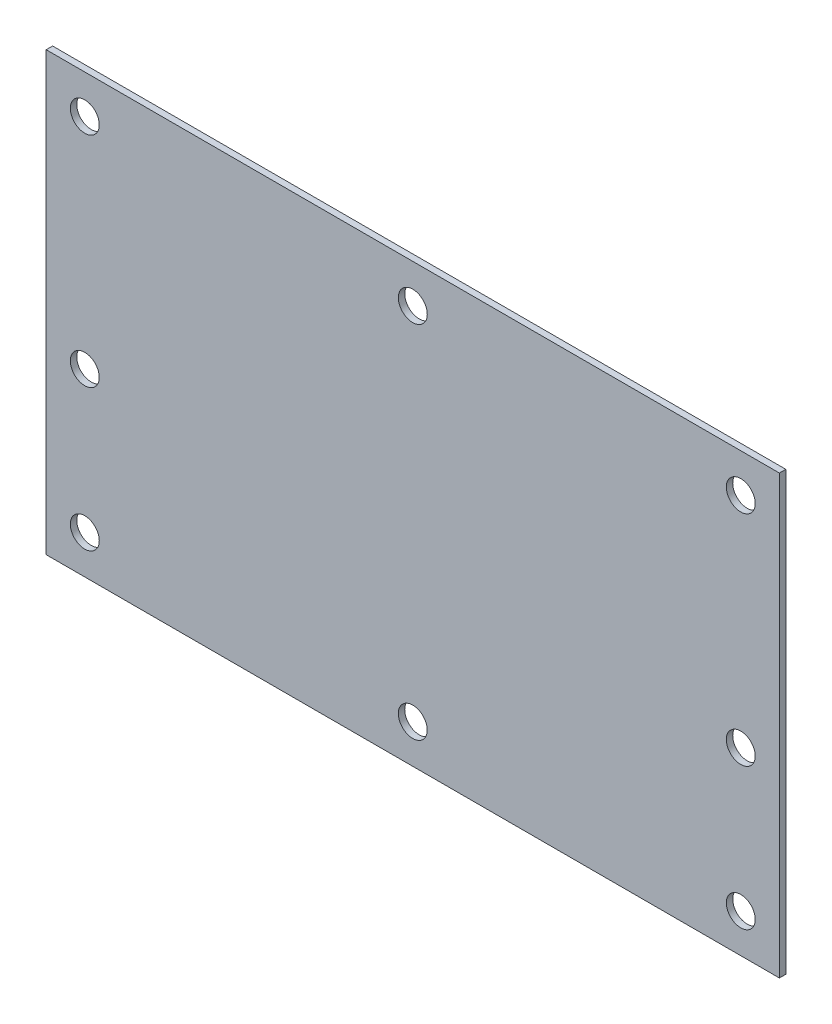
from build123d import *

# Parameters (mm, degrees)
SKETCH_1_W          = 114
SKETCH_1_H          = 68
EXTRUDE_1_DEPTH     = 1
CUT_EXTRUDE_1_REACH = 3
SKETCH_2_R          = 2.25


with BuildPart() as part:
    # Эскиз1 → Бобышка-Вытянуть1 (new body)
    with BuildSketch(Plane.XY):
        with Locations((57, 34)):
            Rectangle(SKETCH_1_W, SKETCH_1_H)
    extrude(amount=EXTRUDE_1_DEPTH)

    # Эскиз2 → Вырез-Вытянуть1 (cut, up to next)
    with BuildSketch(Plane.XY.offset(1), mode=Mode.PRIVATE) as cut_extrude_1_sk1:
        with Locations((6, 62)):
            Circle(SKETCH_2_R)
    cut_extrude_1_tool1 = extrude(cut_extrude_1_sk1.sketch, amount=-CUT_EXTRUDE_1_REACH, mode=Mode.PRIVATE) & part.part
    add(cut_extrude_1_tool1.solids().sort_by_distance((6, 62, 1))[0], mode=Mode.SUBTRACT)
    # Эскиз2 → Вырез-Вытянуть1 (cut, up to next)
    with BuildSketch(Plane.XY.offset(1), mode=Mode.PRIVATE) as cut_extrude_1_sk2:
        with Locations((6, 28)):
            Circle(SKETCH_2_R)
    cut_extrude_1_tool2 = extrude(cut_extrude_1_sk2.sketch, amount=-CUT_EXTRUDE_1_REACH, mode=Mode.PRIVATE) & part.part
    add(cut_extrude_1_tool2.solids().sort_by_distance((6, 28, 1))[0], mode=Mode.SUBTRACT)
    # Эскиз2 → Вырез-Вытянуть1 (cut, up to next)
    with BuildSketch(Plane.XY.offset(1), mode=Mode.PRIVATE) as cut_extrude_1_sk3:
        with Locations((6, 6)):
            Circle(SKETCH_2_R)
    cut_extrude_1_tool3 = extrude(cut_extrude_1_sk3.sketch, amount=-CUT_EXTRUDE_1_REACH, mode=Mode.PRIVATE) & part.part
    add(cut_extrude_1_tool3.solids().sort_by_distance((6, 6, 1))[0], mode=Mode.SUBTRACT)
    # Эскиз2 → Вырез-Вытянуть1 (cut, up to next)
    with BuildSketch(Plane.XY.offset(1), mode=Mode.PRIVATE) as cut_extrude_1_sk4:
        with Locations((57, 6)):
            Circle(SKETCH_2_R)
    cut_extrude_1_tool4 = extrude(cut_extrude_1_sk4.sketch, amount=-CUT_EXTRUDE_1_REACH, mode=Mode.PRIVATE) & part.part
    add(cut_extrude_1_tool4.solids().sort_by_distance((57, 6, 1))[0], mode=Mode.SUBTRACT)
    # Эскиз2 → Вырез-Вытянуть1 (cut, up to next)
    with BuildSketch(Plane.XY.offset(1), mode=Mode.PRIVATE) as cut_extrude_1_sk5:
        with Locations((57, 62)):
            Circle(SKETCH_2_R)
    cut_extrude_1_tool5 = extrude(cut_extrude_1_sk5.sketch, amount=-CUT_EXTRUDE_1_REACH, mode=Mode.PRIVATE) & part.part
    add(cut_extrude_1_tool5.solids().sort_by_distance((57, 62, 1))[0], mode=Mode.SUBTRACT)
    # Эскиз2 → Вырез-Вытянуть1 (cut, up to next)
    with BuildSketch(Plane.XY.offset(1), mode=Mode.PRIVATE) as cut_extrude_1_sk6:
        with Locations((108, 62)):
            Circle(SKETCH_2_R)
    cut_extrude_1_tool6 = extrude(cut_extrude_1_sk6.sketch, amount=-CUT_EXTRUDE_1_REACH, mode=Mode.PRIVATE) & part.part
    add(cut_extrude_1_tool6.solids().sort_by_distance((108, 62, 1))[0], mode=Mode.SUBTRACT)
    # Эскиз2 → Вырез-Вытянуть1 (cut, up to next)
    with BuildSketch(Plane.XY.offset(1), mode=Mode.PRIVATE) as cut_extrude_1_sk7:
        with Locations((108, 28)):
            Circle(SKETCH_2_R)
    cut_extrude_1_tool7 = extrude(cut_extrude_1_sk7.sketch, amount=-CUT_EXTRUDE_1_REACH, mode=Mode.PRIVATE) & part.part
    add(cut_extrude_1_tool7.solids().sort_by_distance((108, 28, 1))[0], mode=Mode.SUBTRACT)
    # Эскиз2 → Вырез-Вытянуть1 (cut, up to next)
    with BuildSketch(Plane.XY.offset(1), mode=Mode.PRIVATE) as cut_extrude_1_sk8:
        with Locations((108, 6)):
            Circle(SKETCH_2_R)
    cut_extrude_1_tool8 = extrude(cut_extrude_1_sk8.sketch, amount=-CUT_EXTRUDE_1_REACH, mode=Mode.PRIVATE) & part.part
    add(cut_extrude_1_tool8.solids().sort_by_distance((108, 6, 1))[0], mode=Mode.SUBTRACT)


solid = part.part
